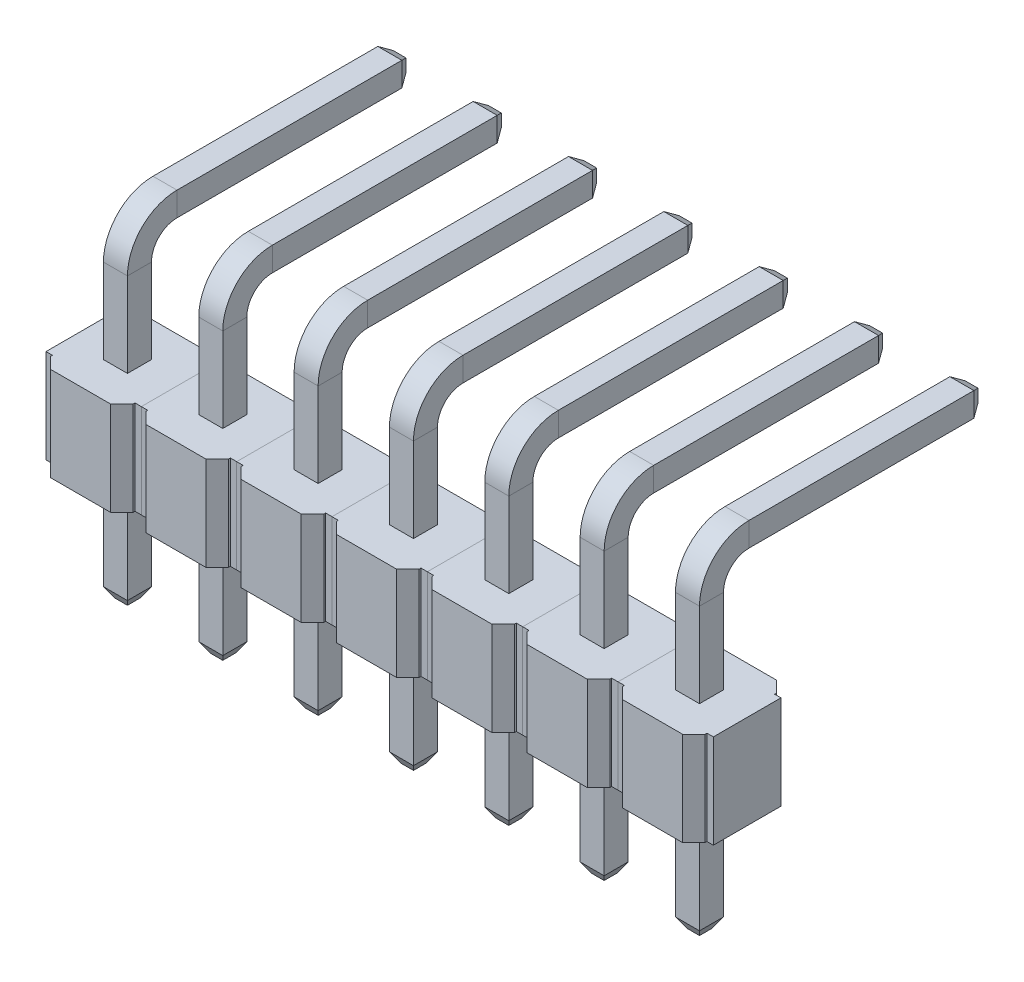
from build123d import *

# Parameters (mm, degrees)
SKETCH_3_W             = 0.64
SKETCH_3_H             = 0.64
CHAMFER_1_SIZE         = 0.15
CHAMFER_1_SIZE2        = 0.259807621
CHAMFER_1_PART_2_SIZE  = 0.15
CHAMFER_1_PART_2_SIZE2 = 0.259807621
EXTRUDE_1_DEPTH        = 2.5
CHAMFER_2_SIZE         = 0.3
PATTERN_LINEAR_1_COUNT = 7
PATTERN_LINEAR_1_PITCH = 2.54


with BuildPart() as part:
    # По траектории1: sweep along a path in Эскиз2
    with BuildLine(Plane(origin=(0, 0, 0), x_dir=(0, 0, -1), z_dir=(1, 0, 0))) as sweep_1_path:
        Line((0, -3), (0, 0))
        Line((0, 0), (0, 4.75))
        ThreePointArc((0, 4.75), (0.292893219, 5.457106781), (1, 5.75))
        Line((1, 5.75), (7.25, 5.75))
    # Эскиз3 → По траектории1 (sweep)
    with BuildSketch(Plane(origin=(0, 0, 0), x_dir=(1, 0, 0), z_dir=(0, 1, 0))):
        Rectangle(SKETCH_3_W, SKETCH_3_H)
    sweep(path=sweep_1_path.line)

    # Фаска1
    chamfer_1_edges = [part.edges().sort_by_distance(p)[0] for p in [
        (0, 5.43, -7.25),
        (-0.32, 5.75, -7.25),
        (0, 6.07, -7.25),
        (0.32, 5.75, -7.25),
    ]]
    chamfer_1_side = [part.faces().sort_by_distance(p)[0] for p in [
        (0, 5.75, -7.25),
    ]]
    chamfer(chamfer_1_edges, length=CHAMFER_1_SIZE, length2=CHAMFER_1_SIZE2, reference=chamfer_1_side[0])

    # Фаска1 part 2
    chamfer_1_part_2_edges = [part.edges().sort_by_distance(p)[0] for p in [
        (0.32, -3, 0),
        (0, -3, -0.32),
        (-0.32, -3, 0),
        (0, -3, 0.32),
    ]]
    chamfer_1_part_2_side = [part.faces().sort_by_distance(p)[0] for p in [
        (0, -3, 0),
    ]]
    chamfer(chamfer_1_part_2_edges, length=CHAMFER_1_PART_2_SIZE, length2=CHAMFER_1_PART_2_SIZE2, reference=chamfer_1_part_2_side[0])


with BuildPart() as body_2:
    # Эскиз4 → Бобышка-Вытянуть1 (new body)
    with BuildSketch(Plane(origin=(0, 0, 0), x_dir=(1, 0, 0), z_dir=(0, 1, 0))):
        Polygon((-1.1, 0.9), (-1.1, 1.25), (1.1, 1.25), (1.1, 0.9), (1.27, 0.9), (1.27, -0.9), (1.1, -0.9), (1.1, -1.25), (-1.1, -1.25), (-1.1, -0.9), (-1.27, -0.9), (-1.27, 0.9), align=None)
    extrude(amount=EXTRUDE_1_DEPTH)

    # Фаска2
    chamfer_2_edges = [body_2.edges().sort_by_distance(p)[0] for p in [
        (1.1, 1.25, 1.25),
        (-1.1, 1.25, 1.25),
        (-1.1, 1.25, -1.25),
        (1.1, 1.25, -1.25),
    ]]
    chamfer(chamfer_2_edges, length=CHAMFER_2_SIZE)


with BuildPart() as pattern_linear_1_1:
    # Линейный массив1: pattern copy
    add(body_2.part.moved(Location(Vector(-1, 0, 0) * (1 * PATTERN_LINEAR_1_PITCH))))


with BuildPart() as pattern_linear_1_2:
    # Линейный массив1: pattern copy
    add(body_2.part.moved(Location(Vector(-1, 0, 0) * (2 * PATTERN_LINEAR_1_PITCH))))


with BuildPart() as pattern_linear_1_3:
    # Линейный массив1: pattern copy
    add(body_2.part.moved(Location(Vector(-1, 0, 0) * (3 * PATTERN_LINEAR_1_PITCH))))


with BuildPart() as pattern_linear_1_4:
    # Линейный массив1: pattern copy
    add(body_2.part.moved(Location(Vector(-1, 0, 0) * (4 * PATTERN_LINEAR_1_PITCH))))


with BuildPart() as pattern_linear_1_5:
    # Линейный массив1: pattern copy
    add(body_2.part.moved(Location(Vector(-1, 0, 0) * (5 * PATTERN_LINEAR_1_PITCH))))


with BuildPart() as pattern_linear_1_6:
    # Линейный массив1: pattern copy
    add(body_2.part.moved(Location(Vector(-1, 0, 0) * (6 * PATTERN_LINEAR_1_PITCH))))


with BuildPart() as pattern_linear_1_7:
    # Линейный массив1: pattern copy
    add(part.part.moved(Location(Vector(-1, 0, 0) * (1 * PATTERN_LINEAR_1_PITCH))))


with BuildPart() as pattern_linear_1_8:
    # Линейный массив1: pattern copy
    add(part.part.moved(Location(Vector(-1, 0, 0) * (2 * PATTERN_LINEAR_1_PITCH))))


with BuildPart() as pattern_linear_1_9:
    # Линейный массив1: pattern copy
    add(part.part.moved(Location(Vector(-1, 0, 0) * (3 * PATTERN_LINEAR_1_PITCH))))


with BuildPart() as pattern_linear_1_10:
    # Линейный массив1: pattern copy
    add(part.part.moved(Location(Vector(-1, 0, 0) * (4 * PATTERN_LINEAR_1_PITCH))))


with BuildPart() as pattern_linear_1_11:
    # Линейный массив1: pattern copy
    add(part.part.moved(Location(Vector(-1, 0, 0) * (5 * PATTERN_LINEAR_1_PITCH))))


with BuildPart() as pattern_linear_1_12:
    # Линейный массив1: pattern copy
    add(part.part.moved(Location(Vector(-1, 0, 0) * (6 * PATTERN_LINEAR_1_PITCH))))


solid = Compound([part.part, body_2.part, pattern_linear_1_1.part, pattern_linear_1_2.part, pattern_linear_1_3.part, pattern_linear_1_4.part, pattern_linear_1_5.part, pattern_linear_1_6.part, pattern_linear_1_7.part, pattern_linear_1_8.part, pattern_linear_1_9.part, pattern_linear_1_10.part, pattern_linear_1_11.part, pattern_linear_1_12.part])
